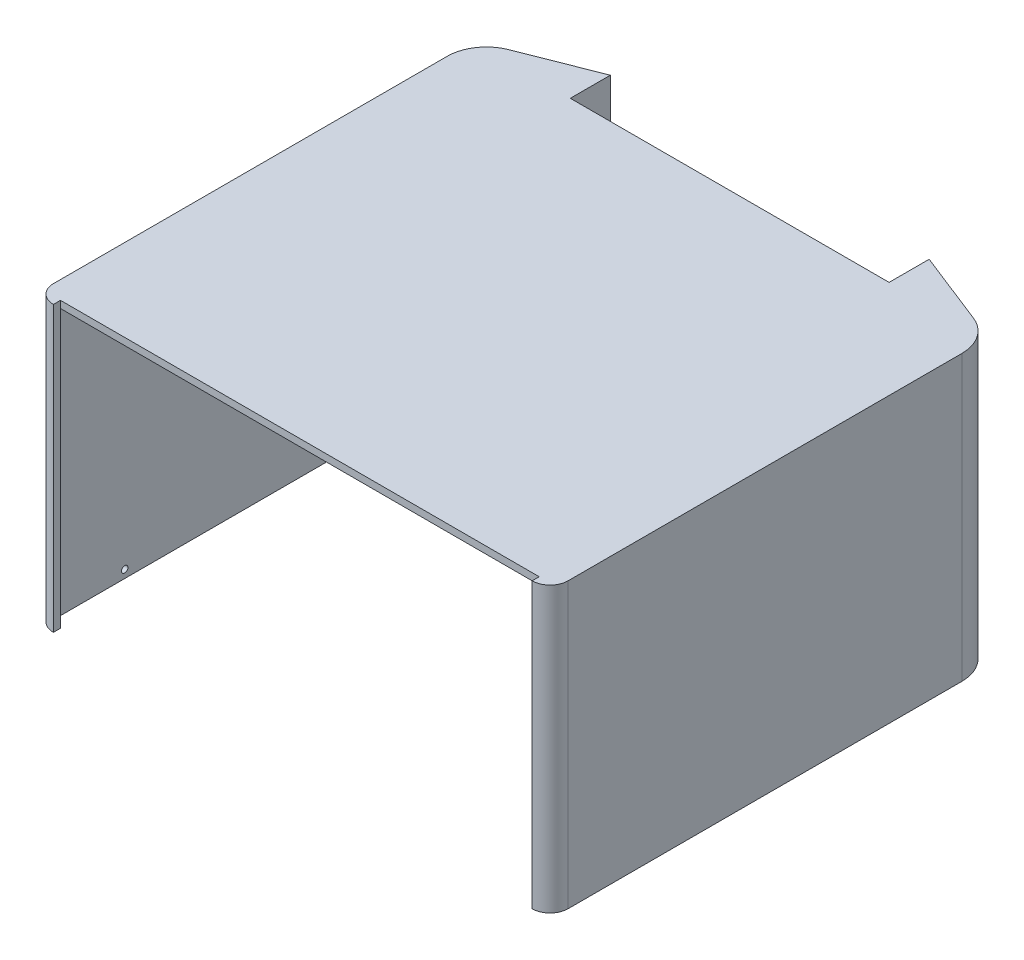
from build123d import *

# Parameters (mm, degrees)
BOSS_EXTRUDE2_DEPTH  = 82
BOSS_EXTRUDE3_DEPTH  = 1.5
SKETCH4_W            = 149
SKETCH4_H            = 82
CUT_EXTRUDE2_DEPTH   = 1.5
SKETCH5_W            = 99.231457505
SKETCH5_H            = 0.2
CUT_EXTRUDE3_DEPTH   = 18
SKETCH6_R            = 1
CUT_EXTRUDE4_DEPTH   = 243
CUT_EXTRUDE5_DEPTH   = 16.4
BOSS_EXTRUDE4_DEPTH  = 5
BOSS_EXTRUDE6_DEPTH  = 1.4
SKETCH10_W           = 99.231457505
SKETCH10_H           = 5.34
SKETCH10_H_2         = 1.4
BOSS_EXTRUDE7_DEPTH  = 1.4
BOSS_EXTRUDE8_DEPTH  = 88.4
BOSS_EXTRUDE9_DEPTH  = 0.8
SKETCH13_W           = 10.944457325
SKETCH13_H           = 86.2
BOSS_EXTRUDE10_DEPTH = 0.8


with BuildPart() as part:
    # Sketch1 → Boss-Extrude2 (new body)
    with BuildSketch(Plane(origin=(0, 0, 0), x_dir=(1, 0, 0), z_dir=(0, 1, 0))):
        with BuildLine():
            Line((-0.443676805, -72.739461341), (-0.443676805, -74.139461341))
            Line((-0.443676805, -74.139461341), (74.056323195, -74.139461341))
            ThreePointArc((74.056323195, -74.139461341), (77.450435745, -72.733573891), (78.856323195, -69.339461341))
            Line((78.856323195, -69.339461341), (78.856323195, -3.839461341))
            Line((78.856323195, -3.839461341), (78.856323195, 53.213038835))
            ThreePointArc((78.856323195, 53.213038835), (76.87852757, 59.630364191), (71.631399559, 63.820995158))
            Line((71.631399559, 63.820995158), (49.172051948, 72.660538659))
            Line((49.172051948, 72.660538659), (49.172051948, 71.156007577))
            Line((49.172051948, 71.156007577), (49.172051948, 59.660538659))
            Line((49.172051948, 59.660538659), (50.572051948, 59.660538659))
            Line((50.572051948, 59.660538659), (50.572051948, 70.604995984))
            Line((50.572051948, 70.604995984), (71.118670883, 62.51826368))
            ThreePointArc((71.118670883, 62.51826368), (75.721414752, 58.842271604), (77.456323195, 53.213038835))
            Line((77.456323195, 53.213038835), (77.456323195, -3.839461341))
            Line((77.456323195, -3.839461341), (77.456323195, -69.339461341))
            ThreePointArc((77.456323195, -69.339461341), (76.460486251, -71.743624398), (74.056323195, -72.739461341))
            Line((74.056323195, -72.739461341), (-0.443676805, -72.739461341))
        make_face()
        with BuildLine():
            Line((-74.943676805, -74.139461341), (-0.443676805, -74.139461341))
            Line((-0.443676805, -74.139461341), (-0.443676805, -72.739461341))
            Line((-0.443676805, -72.739461341), (-74.943676805, -72.739461341))
            ThreePointArc((-74.943676805, -72.739461341), (-77.347839861, -71.743624398), (-78.343676805, -69.339461341))
            Line((-78.343676805, -69.339461341), (-78.343676805, -3.839461341))
            Line((-78.343676805, -3.839461341), (-78.343676805, 53.213038835))
            ThreePointArc((-78.343676805, 53.213038835), (-76.608768361, 58.842271604), (-72.006024493, 62.51826368))
            Line((-72.006024493, 62.51826368), (-51.459405557, 70.604995984))
            Line((-51.459405557, 70.604995984), (-51.459405557, 59.660538659))
            Line((-51.459405557, 59.660538659), (-50.059405557, 59.660538659))
            Line((-50.059405557, 59.660538659), (-50.059405557, 71.156007577))
            Line((-50.059405557, 71.156007577), (-50.059405557, 72.660538659))
            Line((-50.059405557, 72.660538659), (-72.518753169, 63.820995158))
            ThreePointArc((-72.518753169, 63.820995158), (-77.765881179, 59.630364191), (-79.743676805, 53.213038835))
            Line((-79.743676805, 53.213038835), (-79.743676805, -3.839461341))
            Line((-79.743676805, -3.839461341), (-79.743676805, -69.339461341))
            ThreePointArc((-79.743676805, -69.339461341), (-78.337789355, -72.733573891), (-74.943676805, -74.139461341))
        make_face()
    extrude(amount=BOSS_EXTRUDE2_DEPTH)

    # Sketch3 → Boss-Extrude3 (add)
    with BuildSketch(Plane(origin=(0, 82, 0), x_dir=(1, 0, 0), z_dir=(0, 1, 0))):
        with BuildLine():
            Line((-50.059405557, 59.660538659), (49.172051948, 59.660538659))
            Line((49.172051948, 59.660538659), (50.572051948, 59.660538659))
            Line((50.572051948, 59.660538659), (50.572051948, 70.604995984))
            Line((50.572051948, 70.604995984), (71.118670883, 62.51826368))
            ThreePointArc((71.118670883, 62.51826368), (75.721414752, 58.842271604), (77.456323195, 53.213038835))
            Line((77.456323195, 53.213038835), (77.456323195, -69.339461341))
            ThreePointArc((77.456323195, -69.339461341), (76.460486251, -71.743624398), (74.056323195, -72.739461341))
            Line((74.056323195, -72.739461341), (-74.943676805, -72.739461341))
            ThreePointArc((-74.943676805, -72.739461341), (-77.347839861, -71.743624398), (-78.343676805, -69.339461341))
            Line((-78.343676805, -69.339461341), (-78.343676805, 53.213038835))
            ThreePointArc((-78.343676805, 53.213038835), (-76.608768361, 58.842271604), (-72.006024493, 62.51826368))
            Line((-72.006024493, 62.51826368), (-51.459405557, 70.604995984))
            Line((-51.459405557, 70.604995984), (-51.459405557, 59.660538659))
            Line((-51.459405557, 59.660538659), (-50.059405557, 59.660538659))
        make_face()
    extrude(amount=-BOSS_EXTRUDE3_DEPTH)

    # Sketch4 → Cut-Extrude2 (cut)
    with BuildSketch(Plane.XY.offset(74.139461341)):
        with Locations((-0.443676805, 41)):
            Rectangle(SKETCH4_W, SKETCH4_H)
    extrude(amount=-CUT_EXTRUDE2_DEPTH, mode=Mode.SUBTRACT)

    # Sketch5 → Cut-Extrude3 (cut)
    with BuildSketch(Plane(origin=(0, 82, 0), x_dir=(1, 0, 0), z_dir=(0, 1, 0))):
        with Locations((-0.443676805, 59.560538659)):
            Rectangle(SKETCH5_W, SKETCH5_H)
    extrude(amount=-CUT_EXTRUDE3_DEPTH, mode=Mode.SUBTRACT)

    # Sketch6 → Cut-Extrude4 (cut)
    with BuildSketch(Plane.ZY.offset(79.743676805)):
        with Locations((-33.213038835, 2.5)):
            Circle(SKETCH6_R)
        with Locations((49.339461341, 2.5)):
            Circle(SKETCH6_R)
    extrude(amount=-CUT_EXTRUDE4_DEPTH, mode=Mode.SUBTRACT)

    # Sketch7 → Cut-Extrude5 (cut)
    with BuildSketch(Plane.XZ.offset(-80.5)):
        with BuildLine():
            Line((-50.059405557, -59.460538659), (49.172051948, -59.460538659))
            Line((49.172051948, -59.460538659), (49.172051948, -59.660538659))
            Line((49.172051948, -59.660538659), (50.572051948, -59.660538659))
            Line((50.572051948, -59.660538659), (50.572051948, -70.604995984))
            Line((50.572051948, -70.604995984), (71.118670883, -62.51826368))
            ThreePointArc((71.118670883, -62.51826368), (75.721414752, -58.842271604), (77.456323195, -53.213038835))
            Line((77.456323195, -53.213038835), (77.456323195, 69.339461341))
            ThreePointArc((77.456323195, 69.339461341), (76.460486251, 71.743624398), (74.056323195, 72.739461341))
            Line((74.056323195, 72.739461341), (74.056323195, 72.639461341))
            Line((74.056323195, 72.639461341), (-74.943676805, 72.639461341))
            Line((-74.943676805, 72.639461341), (-74.943676805, 72.739461341))
            ThreePointArc((-74.943676805, 72.739461341), (-77.347839861, 71.743624398), (-78.343676805, 69.339461341))
            Line((-78.343676805, 69.339461341), (-78.343676805, -53.213038835))
            ThreePointArc((-78.343676805, -53.213038835), (-76.608768361, -58.842271604), (-72.006024493, -62.51826368))
            Line((-72.006024493, -62.51826368), (-51.459405557, -70.604995984))
            Line((-51.459405557, -70.604995984), (-51.459405557, -59.660538659))
            Line((-51.459405557, -59.660538659), (-50.059405557, -59.660538659))
            Line((-50.059405557, -59.660538659), (-50.059405557, -59.460538659))
        make_face()
    extrude(amount=-CUT_EXTRUDE5_DEPTH, mode=Mode.SUBTRACT)

    # Sketch8 → Boss-Extrude4 (add)
    with BuildSketch(Plane(origin=(0, 82, 0), x_dir=(1, 0, 0), z_dir=(0, 1, 0))):
        with BuildLine():
            Line((74.056323195, -72.739461341), (74.056323195, -74.139461341))
            ThreePointArc((74.056323195, -74.139461341), (77.450435745, -72.733573891), (78.856323195, -69.339461341))
            Line((78.856323195, -69.339461341), (78.856323195, 53.213038835))
            ThreePointArc((78.856323195, 53.213038835), (76.87852757, 59.630364191), (71.631399559, 63.820995158))
            Line((71.631399559, 63.820995158), (49.172051948, 72.660538659))
            Line((49.172051948, 72.660538659), (49.172051948, 59.660538659))
            Line((49.172051948, 59.660538659), (50.572051948, 59.660538659))
            Line((50.572051948, 59.660538659), (50.572051948, 70.604995984))
            Line((50.572051948, 70.604995984), (71.118670883, 62.51826368))
            ThreePointArc((71.118670883, 62.51826368), (75.721414752, 58.842271604), (77.456323195, 53.213038835))
            Line((77.456323195, 53.213038835), (77.456323195, -69.339461341))
            ThreePointArc((77.456323195, -69.339461341), (76.460486251, -71.743624398), (74.056323195, -72.739461341))
        make_face()
        with BuildLine():
            Line((-51.459405557, 59.660538659), (-50.059405557, 59.660538659))
            Line((-50.059405557, 59.660538659), (-50.059405557, 72.660538659))
            Line((-50.059405557, 72.660538659), (-72.518753169, 63.820995158))
            ThreePointArc((-72.518753169, 63.820995158), (-77.765881179, 59.630364191), (-79.743676805, 53.213038835))
            Line((-79.743676805, 53.213038835), (-79.743676805, -69.339461341))
            ThreePointArc((-79.743676805, -69.339461341), (-78.337789355, -72.733573891), (-74.943676805, -74.139461341))
            Line((-74.943676805, -74.139461341), (-74.943676805, -72.739461341))
            ThreePointArc((-74.943676805, -72.739461341), (-77.347839861, -71.743624398), (-78.343676805, -69.339461341))
            Line((-78.343676805, -69.339461341), (-78.343676805, 53.213038835))
            ThreePointArc((-78.343676805, 53.213038835), (-76.608768361, 58.842271604), (-72.006024493, 62.51826368))
            Line((-72.006024493, 62.51826368), (-51.459405557, 70.604995984))
            Line((-51.459405557, 70.604995984), (-51.459405557, 59.660538659))
        make_face()
    extrude(amount=BOSS_EXTRUDE4_DEPTH)

    # Sketch9 → Boss-Extrude6 (add)
    with BuildSketch(Plane(origin=(0, 87, 0), x_dir=(1, 0, 0), z_dir=(0, 1, 0))):
        with BuildLine():
            Line((77.456323195, 53.213038835), (77.456323195, -69.339461341))
            ThreePointArc((77.456323195, -69.339461341), (76.460486251, -71.743624398), (74.056323195, -72.739461341))
            Line((74.056323195, -72.739461341), (-74.943676805, -72.739461341))
            ThreePointArc((-74.943676805, -72.739461341), (-77.347839861, -71.743624398), (-78.343676805, -69.339461341))
            Line((-78.343676805, -69.339461341), (-78.343676805, 53.213038835))
            ThreePointArc((-78.343676805, 53.213038835), (-76.608768361, 58.842271604), (-72.006024493, 62.51826368))
            Line((-72.006024493, 62.51826368), (-51.459405557, 70.604995984))
            Line((-51.459405557, 70.604995984), (-51.459405557, 59.660538659))
            Line((-51.459405557, 59.660538659), (-50.059405557, 59.660538659))
            Line((-50.059405557, 59.660538659), (49.172051948, 59.660538659))
            Line((49.172051948, 59.660538659), (50.572051948, 59.660538659))
            Line((50.572051948, 59.660538659), (50.572051948, 70.604995984))
            Line((50.572051948, 70.604995984), (71.118670883, 62.51826368))
            ThreePointArc((71.118670883, 62.51826368), (75.721414752, 58.842271604), (77.456323195, 53.213038835))
        make_face()
        with BuildLine():
            Line((-72.006024493, 62.51826368), (-51.459405557, 70.604995984))
            Line((-51.459405557, 70.604995984), (-51.459405557, 59.660538659))
            Line((-51.459405557, 59.660538659), (-50.059405557, 59.660538659))
            Line((-50.059405557, 59.660538659), (-50.059405557, 72.660538659))
            Line((-50.059405557, 72.660538659), (-72.518753169, 63.820995158))
            ThreePointArc((-72.518753169, 63.820995158), (-77.765881179, 59.630364191), (-79.743676805, 53.213038835))
            Line((-79.743676805, 53.213038835), (-79.743676805, -69.339461341))
            ThreePointArc((-79.743676805, -69.339461341), (-78.337789355, -72.733573891), (-74.943676805, -74.139461341))
            Line((-74.943676805, -74.139461341), (-74.943676805, -72.739461341))
            ThreePointArc((-74.943676805, -72.739461341), (-77.347839861, -71.743624398), (-78.343676805, -69.339461341))
            Line((-78.343676805, -69.339461341), (-78.343676805, 53.213038835))
            ThreePointArc((-78.343676805, 53.213038835), (-76.608768361, 58.842271604), (-72.006024493, 62.51826368))
        make_face()
        with BuildLine():
            ThreePointArc((77.456323195, 53.213038835), (75.721414752, 58.842271604), (71.118670883, 62.51826368))
            Line((71.118670883, 62.51826368), (50.572051948, 70.604995984))
            Line((50.572051948, 70.604995984), (50.572051948, 59.660538659))
            Line((50.572051948, 59.660538659), (49.172051948, 59.660538659))
            Line((49.172051948, 59.660538659), (49.172051948, 72.660538659))
            Line((49.172051948, 72.660538659), (71.631399559, 63.820995158))
            ThreePointArc((71.631399559, 63.820995158), (76.87852757, 59.630364191), (78.856323195, 53.213038835))
            Line((78.856323195, 53.213038835), (78.856323195, -69.339461341))
            ThreePointArc((78.856323195, -69.339461341), (77.450435745, -72.733573891), (74.056323195, -74.139461341))
            Line((74.056323195, -74.139461341), (74.056323195, -72.739461341))
            ThreePointArc((74.056323195, -72.739461341), (76.460486251, -71.743624398), (77.456323195, -69.339461341))
            Line((77.456323195, -69.339461341), (77.456323195, 53.213038835))
        make_face()
    extrude(amount=BOSS_EXTRUDE6_DEPTH)

    # Sketch10 → Boss-Extrude7 (add)
    with BuildSketch(Plane(origin=(0, 0, -59.660538659), x_dir=(-1, 0, 0), z_dir=(0, 0, -1))):
        with Locations((0.443676805, 84.33)):
            Rectangle(SKETCH10_W, SKETCH10_H)
        with Locations((0.443676805, 87.7)):
            Rectangle(SKETCH10_W, SKETCH10_H_2)
    extrude(amount=BOSS_EXTRUDE7_DEPTH)

    # Sketch11 → Boss-Extrude8 (add)
    with BuildSketch(Plane(origin=(0, 88.4, 0), x_dir=(1, 0, 0), z_dir=(0, 1, 0))):
        with BuildLine():
            Line((71.924387374, 64.565413146), (49.172051948, 73.520270705))
            Line((49.172051948, 73.520270705), (49.172051948, 72.660538659))
            Line((49.172051948, 72.660538659), (71.631399559, 63.820995158))
            ThreePointArc((71.631399559, 63.820995158), (76.87852757, 59.630364191), (78.856323195, 53.213038835))
            Line((78.856323195, 53.213038835), (78.856323195, -69.339461341))
            ThreePointArc((78.856323195, -69.339461341), (77.450435745, -72.733573891), (74.056323195, -74.139461341))
            Line((74.056323195, -74.139461341), (74.056323195, -74.939461341))
            ThreePointArc((74.056323195, -74.939461341), (78.01612117, -73.299259316), (79.656323195, -69.339461341))
            Line((79.656323195, -69.339461341), (79.656323195, 53.213038835))
            ThreePointArc((79.656323195, 53.213038835), (77.539734894, 60.080702813), (71.924387374, 64.565413146))
        make_face()
        with BuildLine():
            Line((-50.059405557, 72.660538659), (-50.059405557, 73.520270705))
            Line((-50.059405557, 73.520270705), (-72.811740984, 64.565413146))
            ThreePointArc((-72.811740984, 64.565413146), (-78.427088504, 60.080702813), (-80.543676805, 53.213038835))
            Line((-80.543676805, 53.213038835), (-80.543676805, -69.339461341))
            ThreePointArc((-80.543676805, -69.339461341), (-78.90347478, -73.299259316), (-74.943676805, -74.939461341))
            Line((-74.943676805, -74.939461341), (-74.943676805, -74.139461341))
            ThreePointArc((-74.943676805, -74.139461341), (-78.337789355, -72.733573891), (-79.743676805, -69.339461341))
            Line((-79.743676805, -69.339461341), (-79.743676805, 53.213038835))
            ThreePointArc((-79.743676805, 53.213038835), (-77.765881179, 59.630364191), (-72.518753169, 63.820995158))
            Line((-72.518753169, 63.820995158), (-50.059405557, 72.660538659))
        make_face()
    extrude(amount=-BOSS_EXTRUDE8_DEPTH)

    # Sketch12 → Boss-Extrude9 (add)
    with BuildSketch(Plane.XZ.offset(-87)):
        with BuildLine():
            Line((-51.459405557, -59.660538659), (50.572051948, -59.660538659))
            Line((50.572051948, -59.660538659), (50.572051948, -70.604995984))
            Line((50.572051948, -70.604995984), (71.118670883, -62.51826368))
            ThreePointArc((71.118670883, -62.51826368), (75.721414752, -58.842271604), (77.456323195, -53.213038835))
            Line((77.456323195, -53.213038835), (77.456323195, 69.339461341))
            ThreePointArc((77.456323195, 69.339461341), (76.460486251, 71.743624398), (74.056323195, 72.739461341))
            Line((74.056323195, 72.739461341), (-74.943676805, 72.739461341))
            ThreePointArc((-74.943676805, 72.739461341), (-77.347839861, 71.743624398), (-78.343676805, 69.339461341))
            Line((-78.343676805, 69.339461341), (-78.343676805, -53.213038835))
            ThreePointArc((-78.343676805, -53.213038835), (-76.608768361, -58.842271604), (-72.006024493, -62.51826368))
            Line((-72.006024493, -62.51826368), (-51.459405557, -70.604995984))
            Line((-51.459405557, -70.604995984), (-51.459405557, -59.660538659))
        make_face()
    extrude(amount=BOSS_EXTRUDE9_DEPTH)

    # Sketch13 → Boss-Extrude10 (add)
    with BuildSketch(Plane.ZY.offset(51.459405557)):
        with Locations((-65.132767321, 43.1)):
            Rectangle(SKETCH13_W, SKETCH13_H)
    extrude(amount=BOSS_EXTRUDE10_DEPTH)


solid = part.part
